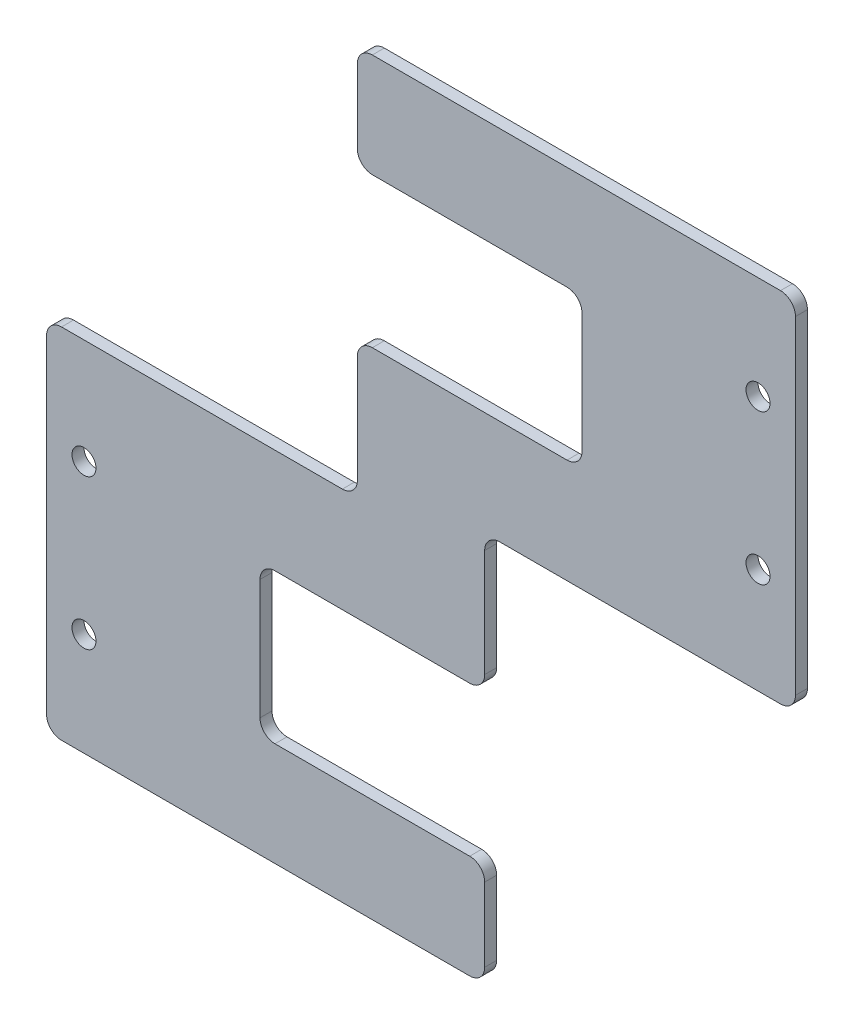
from build123d import *

# Parameters (mm, degrees)
SKETCH_1_R      = 1.6
EXTRUDE_1_DEPTH = 1.6
FILLET_1_R      = 2


with BuildPart() as part:
    # 草图1 → 凸台-拉伸1 (new body)
    with BuildSketch(Plane.XY):
        Polygon((8.5, 2.2), (8.5, -16.15), (-21.5, -16.15), (-21.5, -36.15), (8.5, -36.15), (8.5, -50), (-50, -50), (-50, -2.2), (-8.5, -2.2), (-8.5, 16.15), (21.5, 16.15), (21.5, 36.15), (-8.5, 36.15), (-8.5, 50), (50, 50), (50, 2.2), align=None)
        with Locations((-45, -36.25)):
            Circle(SKETCH_1_R, mode=Mode.SUBTRACT)
        with Locations((-45, -16.25)):
            Circle(SKETCH_1_R, mode=Mode.SUBTRACT)
        with Locations((45, 16.25)):
            Circle(SKETCH_1_R, mode=Mode.SUBTRACT)
        with Locations((45, 36.25)):
            Circle(SKETCH_1_R, mode=Mode.SUBTRACT)
    extrude(amount=EXTRUDE_1_DEPTH)

    # 圆角1
    fillet_1_edges = [part.edges().sort_by_distance(p)[0] for p in [
        (8.5, 2.2, 0.8),
        (8.5, -16.15, 0.8),
        (-21.5, -16.15, 0.8),
        (-21.5, -36.15, 0.8),
        (8.5, -36.15, 0.8),
        (8.5, -50, 0.8),
        (-50, -50, 0.8),
        (-50, -2.2, 0.8),
        (-8.5, -2.2, 0.8),
        (-8.5, 16.15, 0.8),
        (21.5, 16.15, 0.8),
        (21.5, 36.15, 0.8),
        (-8.5, 36.15, 0.8),
        (-8.5, 50, 0.8),
        (50, 50, 0.8),
        (50, 2.2, 0.8),
    ]]
    fillet(fillet_1_edges, radius=FILLET_1_R)


solid = part.part
